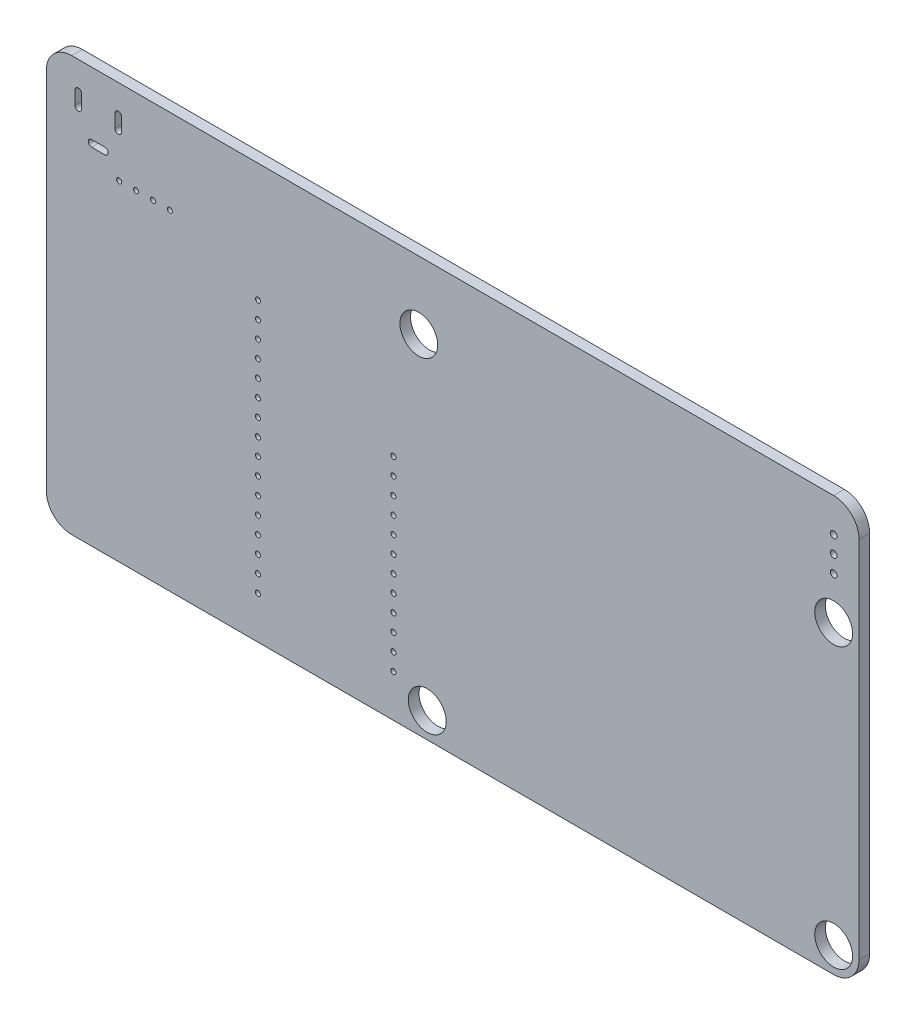
from build123d import *

# Parameters (mm, degrees)
ESQUISSE1_R        = 0.381
ESQUISSE1_R_2      = 2.839806331
ESQUISSE1_R_3      = 0.5
BOSS_EXTRU_1_DEPTH = 1.6


with BuildPart() as part:
    # Esquisse1 → Boss.-Extru.1 (new body)
    with BuildSketch(Plane.XY.offset(1.6)):
        with BuildLine():
            Line((146.05, -111.76), (146.05, -57.15))
            ThreePointArc((146.05, -57.15), (144.934076836, -54.455923164), (142.24, -53.34))
            Line((142.24, -53.34), (27.94, -53.34))
            ThreePointArc((27.94, -53.34), (25.245923164, -54.455923164), (24.13, -57.15))
            Line((24.13, -57.15), (24.13, -111.76))
            ThreePointArc((24.13, -111.76), (25.245923164, -114.454076836), (27.94, -115.57))
            Line((27.94, -115.57), (142.24, -115.57))
            ThreePointArc((142.24, -115.57), (144.934076836, -114.454076836), (146.05, -111.76))
        make_face()
        with Locations((55.88, -109.22)):
            Circle(ESQUISSE1_R, mode=Mode.SUBTRACT)
        with Locations((55.88, -106.68)):
            Circle(ESQUISSE1_R, mode=Mode.SUBTRACT)
        with Locations((142.24, -111.76)):
            Circle(ESQUISSE1_R_2, mode=Mode.SUBTRACT)
        with Locations((81.28, -111.76)):
            Circle(ESQUISSE1_R_2, mode=Mode.SUBTRACT)
        with Locations((76.2, -106.68)):
            Circle(ESQUISSE1_R, mode=Mode.SUBTRACT)
        with Locations((76.2, -109.22)):
            Circle(ESQUISSE1_R, mode=Mode.SUBTRACT)
        with Locations((76.2, -104.14)):
            Circle(ESQUISSE1_R, mode=Mode.SUBTRACT)
        with Locations((55.88, -104.14)):
            Circle(ESQUISSE1_R, mode=Mode.SUBTRACT)
        with Locations((142.24, -58.42)):
            Circle(ESQUISSE1_R_3, mode=Mode.SUBTRACT)
        with Locations((142.24, -69.85)):
            Circle(ESQUISSE1_R_2, mode=Mode.SUBTRACT)
        with Locations((142.24, -60.96)):
            Circle(ESQUISSE1_R_3, mode=Mode.SUBTRACT)
        with Locations((142.24, -63.5)):
            Circle(ESQUISSE1_R_3, mode=Mode.SUBTRACT)
        with Locations((80.01, -63.5)):
            Circle(ESQUISSE1_R_2, mode=Mode.SUBTRACT)
        with Locations((55.88, -71.12)):
            Circle(ESQUISSE1_R, mode=Mode.SUBTRACT)
        with Locations((55.88, -73.66)):
            Circle(ESQUISSE1_R, mode=Mode.SUBTRACT)
        with Locations((55.88, -76.2)):
            Circle(ESQUISSE1_R, mode=Mode.SUBTRACT)
        with Locations((55.88, -78.74)):
            Circle(ESQUISSE1_R, mode=Mode.SUBTRACT)
        with Locations((42.672, -66.04)):
            Circle(ESQUISSE1_R, mode=Mode.SUBTRACT)
        with Locations((35.052, -66.04)):
            Circle(ESQUISSE1_R, mode=Mode.SUBTRACT)
        with Locations((37.592, -66.04)):
            Circle(ESQUISSE1_R, mode=Mode.SUBTRACT)
        with Locations((40.132, -66.04)):
            Circle(ESQUISSE1_R, mode=Mode.SUBTRACT)
        with Locations((76.2, -81.28)):
            Circle(ESQUISSE1_R, mode=Mode.SUBTRACT)
        with Locations((55.88, -81.28)):
            Circle(ESQUISSE1_R, mode=Mode.SUBTRACT)
        with Locations((76.2, -83.82)):
            Circle(ESQUISSE1_R, mode=Mode.SUBTRACT)
        with Locations((76.2, -86.36)):
            Circle(ESQUISSE1_R, mode=Mode.SUBTRACT)
        with Locations((76.2, -88.9)):
            Circle(ESQUISSE1_R, mode=Mode.SUBTRACT)
        with Locations((55.88, -86.36)):
            Circle(ESQUISSE1_R, mode=Mode.SUBTRACT)
        with Locations((55.88, -88.9)):
            Circle(ESQUISSE1_R, mode=Mode.SUBTRACT)
        with Locations((55.88, -83.82)):
            Circle(ESQUISSE1_R, mode=Mode.SUBTRACT)
        with Locations((76.2, -93.98)):
            Circle(ESQUISSE1_R, mode=Mode.SUBTRACT)
        with Locations((55.88, -93.98)):
            Circle(ESQUISSE1_R, mode=Mode.SUBTRACT)
        with Locations((76.2, -91.44)):
            Circle(ESQUISSE1_R, mode=Mode.SUBTRACT)
        with Locations((55.88, -91.44)):
            Circle(ESQUISSE1_R, mode=Mode.SUBTRACT)
        with Locations((76.2, -96.52)):
            Circle(ESQUISSE1_R, mode=Mode.SUBTRACT)
        with Locations((76.2, -99.06)):
            Circle(ESQUISSE1_R, mode=Mode.SUBTRACT)
        with Locations((76.2, -101.6)):
            Circle(ESQUISSE1_R, mode=Mode.SUBTRACT)
        with Locations((55.88, -101.6)):
            Circle(ESQUISSE1_R, mode=Mode.SUBTRACT)
        with Locations((55.88, -99.06)):
            Circle(ESQUISSE1_R, mode=Mode.SUBTRACT)
        with Locations((55.88, -96.52)):
            Circle(ESQUISSE1_R, mode=Mode.SUBTRACT)
        with BuildLine():
            Line((32.925, -63.747), (30.925, -63.747))
            ThreePointArc((30.925, -63.747), (30.425, -63.247), (30.925, -62.747))
            Line((30.925, -62.747), (32.925, -62.747))
            ThreePointArc((32.925, -62.747), (33.425, -63.247), (32.925, -63.747))
        make_face(mode=Mode.SUBTRACT)
        with BuildLine():
            Line((29.425, -57.547), (29.425, -59.547))
            ThreePointArc((29.425, -59.547), (28.925, -60.047), (28.425, -59.547))
            Line((28.425, -59.547), (28.425, -57.547))
            ThreePointArc((28.425, -57.547), (28.925, -57.047), (29.425, -57.547))
        make_face(mode=Mode.SUBTRACT)
        with BuildLine():
            Line((35.425, -57.547), (35.425, -59.547))
            ThreePointArc((35.425, -59.547), (34.925, -60.047), (34.425, -59.547))
            Line((34.425, -59.547), (34.425, -57.547))
            ThreePointArc((34.425, -57.547), (34.925, -57.047), (35.425, -57.547))
        make_face(mode=Mode.SUBTRACT)
    extrude(amount=-BOSS_EXTRU_1_DEPTH)


solid = part.part
